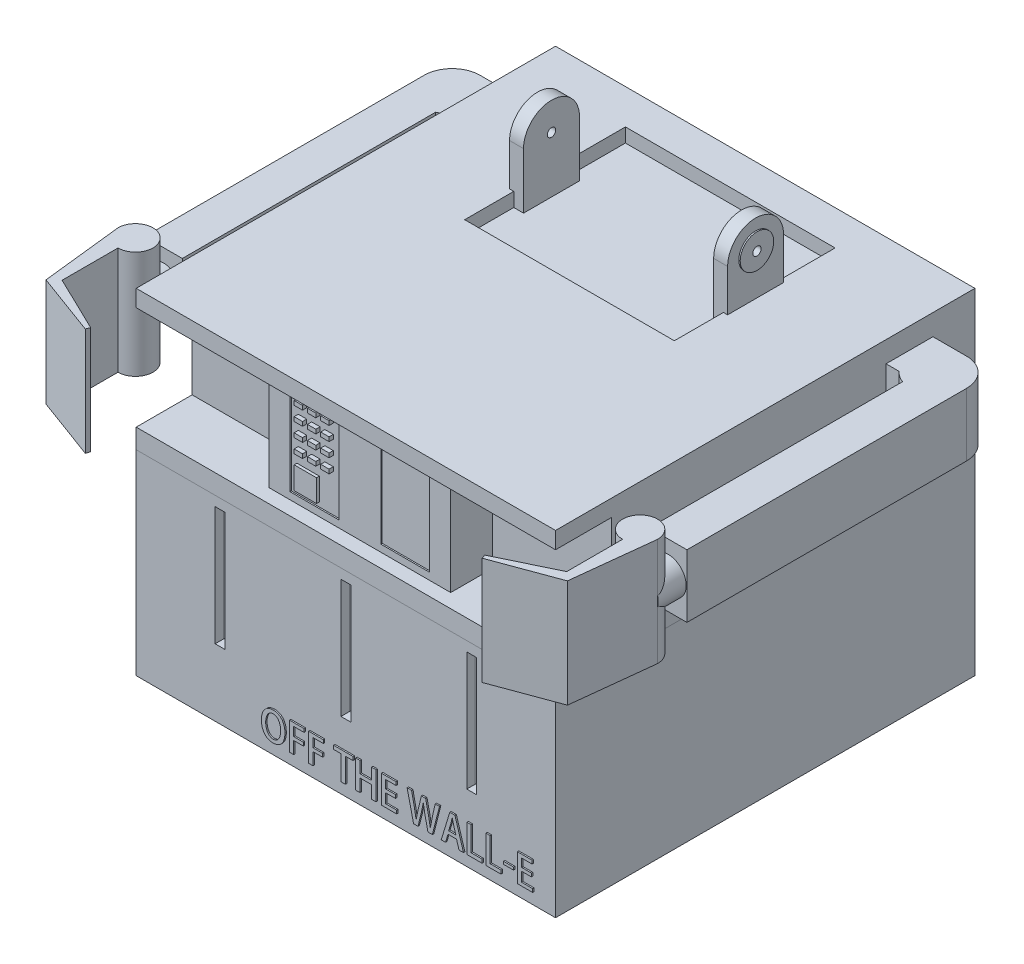
from build123d import *

# Parameters (mm, degrees)
BASE_W                                = 15
BASE_H                                = 15
BOTTOM_BASE_DEPTH                     = 7
BASE2_W                               = 15
BASE2_H                               = 15
TOP_BASE_DEPTH                        = 5
SKETCH3_W                             = 15
SKETCH3_H                             = 3.7
TOP_CUT_DEPTH                         = 2
SKETCH4_W                             = 6.5
SKETCH4_H                             = 3.7
BIG_BUTTON_PLATE_DEPTH                = 1.5
SKETCH6_W                             = 0.3
SKETCH6_H                             = 0.15
F_3X4_BUTTONS_DEPTH                   = 0.1
SKETCH9_W                             = 0.8
SKETCH9_H                             = 0.8
BIG_SQUARE_BUTTON_DEPTH               = 0.1
SKETCH6_6_W                           = 1.75
SKETCH6_6_H                           = 3.2
SKETCH6_6_W_2                         = 0.3
SKETCH6_6_H_2                         = 0.15
PHONE_DEPTH                           = 0.05
SKETCH14_W                            = 0.35
SKETCH14_H                            = 4.25
F_3_BOTTOM_SLOTS_DEPTH                = 0.35
FILLET1_R                             = 0.05
SKETCH15_W                            = 7.5
SKETCH15_H                            = 5.75
TOP_EXTRUDE_CUT_DEPTH                 = 0.5
RIGHT_HEAD_HOLDER_1_DEPTH             = 0.35
RIGHT_HEAD_HOLDER_1_DEPTH_BACK        = 0.15
SKETCH19_R                            = 0.6
RIGHT_HEAD_HOLDER_2_DEPTH             = 0.35
RIGHT_HEAD_HOLDER_2_DEPTH_BACK        = 0.2
SKETCH19_3_R                          = 0.6
SKETCH19_3_R_2                        = 0.15
LEFT_HEAD_HOLDER_1_DEPTH              = 0.35
LEFT_HEAD_HOLDER_1_DEPTH_BACK         = 0.15
SKETCH18_R                            = 0.6
LEFT_HEAD_HOLDER_2_DEPTH              = 0.35
LEFT_HEAD_HOLDER_2_DEPTH_BACK         = 0.2
SKETCH18_3_R                          = 0.6
SKETCH18_3_R_2                        = 0.15
ARMS_DEPTH                            = 2.25
CLAWS_DEPTH                           = 0.8
CLAWS_DEPTH_BACK                      = 3.05
CLAWS_2_DEPTH                         = 0.8
CLAWS_2_DEPTH_BACK                    = 3.05
SKETCH26_R                            = 0.65
CIRCLE_TO_ATTACH_ARMS_AND_CLAWS_DEPTH = 1
SKETCH28_W                            = 0.359189424
SKETCH28_H                            = 0.095238297
BOSS_EXTRUDE26_DEPTH                  = 0.05


with BuildPart() as part:
    # Base → Bottom base (new body)
    with BuildSketch(Plane(origin=(0, 0, 0), x_dir=(1, 0, 0), z_dir=(0, 1, 0))):
        Rectangle(BASE_W, BASE_H)
    extrude(amount=BOTTOM_BASE_DEPTH)

    # Sketch14 → 3 bottom slots (cut)
    with BuildSketch(Plane.XY.offset(7.5)):
        with Locations((0, 4.525)):
            Rectangle(SKETCH14_W, SKETCH14_H)
        with Locations((4.5, 4.525)):
            Rectangle(SKETCH14_W, SKETCH14_H)
        with Locations((-4.5, 4.525)):
            Rectangle(SKETCH14_W, SKETCH14_H)
    extrude(amount=-F_3_BOTTOM_SLOTS_DEPTH, mode=Mode.SUBTRACT)

    # Fillet1
    fillet1_edges = [part.edges().sort_by_distance(p)[0] for p in [
        (-0.175, 4.525, 7.15),
        (-4.675, 4.525, 7.15),
        (4.675, 4.525, 7.15),
        (4.5, 6.65, 7.15),
        (0.175, 4.525, 7.15),
        (0, 6.65, 7.15),
        (4.325, 4.525, 7.15),
        (4.5, 2.4, 7.15),
        (0, 2.4, 7.15),
        (-4.5, 2.4, 7.15),
        (-4.5, 6.65, 7.15),
        (-4.325, 4.525, 7.15),
    ]]
    fillet(fillet1_edges, radius=FILLET1_R)

    # Sketch28 → Boss-Extrude26 (add)
    # profile 1 of 12: a face of its own
    with BuildSketch(Plane.XY.offset(7.5)):
        with BuildLine():
            add(Edge.make_bspline(
                [(-2.542773415, 1.438775136), (-2.55882584, 1.438110923), (-2.59017136, 1.436813916), (-2.635834672, 1.429654226), (-2.678976734, 1.41865114), (-2.719463386, 1.403035452), (-2.757423202, 1.38326681), (-2.792716073, 1.359116703), (-2.825399223, 1.330752787), (-2.855279169, 1.298345473), (-2.882055278, 1.262197262), (-2.905669966, 1.222690536), (-2.925377124, 1.17977718), (-2.941932195, 1.133846801), (-2.954655386, 1.08466898), (-2.964079137, 1.032377645), (-2.969951963, 0.976854424), (-2.97105014, 0.938758011), (-2.971613422, 0.919217401)],
                knots=[0, 0, 0, 0, 1.01693825, 1.985772131, 2.921518734, 3.832117633, 4.727948323, 5.626511184, 6.534414133, 7.463288783, 8.412839634, 9.378967074, 10.373196777, 11.399194858, 12.46754142, 13.586614818, 14.762113956, 16, 16, 16, 16], degree=3))
            add(Edge.make_bspline(
                [(-2.971613422, 0.919217401), (-2.971208289, 0.900429172), (-2.970416523, 0.863710668), (-2.964426968, 0.810220053), (-2.956119813, 0.759588063), (-2.943575482, 0.712087769), (-2.928381776, 0.667333139), (-2.909052276, 0.625858504), (-2.886964026, 0.587076746), (-2.8612577, 0.55170149), (-2.832800775, 0.519545639), (-2.801228268, 0.491619405), (-2.766992422, 0.46781399), (-2.730017847, 0.448191723), (-2.690284694, 0.432873966), (-2.647883002, 0.421784598), (-2.602861971, 0.414647273), (-2.571917352, 0.413420404), (-2.556080466, 0.412792516)],
                knots=[0, 0, 0, 0, 1.222557966, 2.38928844, 3.500048728, 4.559063003, 5.583344684, 6.572073494, 7.532658458, 8.483942143, 9.413076429, 10.322121769, 11.220566177, 12.121066096, 13.040014193, 13.985715855, 14.969126498, 16, 16, 16, 16], degree=3))
            add(Edge.make_bspline(
                [(-2.556080466, 0.412792516), (-2.54075349, 0.413188806), (-2.510669922, 0.41396664), (-2.466682885, 0.420165519), (-2.424842983, 0.430077083), (-2.38526705, 0.444305975), (-2.348009795, 0.462822842), (-2.312864376, 0.485189664), (-2.279982063, 0.511738917), (-2.249253561, 0.542102642), (-2.221648907, 0.576876857), (-2.197202941, 0.615672953), (-2.176945288, 0.65894639), (-2.159942527, 0.706133976), (-2.146555767, 0.757497133), (-2.136920145, 0.812927523), (-2.130587189, 0.872528944), (-2.12942961, 0.913657954), (-2.12883171, 0.934901455)],
                knots=[0, 0, 0, 0, 0.964759122, 1.89361537, 2.791129421, 3.668077106, 4.535429534, 5.405715028, 6.285894481, 7.191747456, 8.120239528, 9.075412678, 10.072429751, 11.12252868, 12.229792465, 13.410030886, 14.662257747, 16, 16, 16, 16], degree=3))
            add(Edge.make_bspline(
                [(-2.12883171, 0.934901455), (-2.129145052, 0.95299104), (-2.12975776, 0.988363246), (-2.134927432, 1.040094869), (-2.143460291, 1.089133126), (-2.154882139, 1.135699503), (-2.169797366, 1.179671389), (-2.188169567, 1.221026594), (-2.209857994, 1.259758826), (-2.234383469, 1.295895008), (-2.262423291, 1.328524563), (-2.293489849, 1.357214635), (-2.327622631, 1.381751634), (-2.365000455, 1.401492806), (-2.405152647, 1.417631026), (-2.44846881, 1.428920554), (-2.494667177, 1.436482788), (-2.526508763, 1.437935279), (-2.542773415, 1.438775136)],
                knots=[0, 0, 0, 0, 1.181997023, 2.311265979, 3.393394717, 4.432710499, 5.441572568, 6.423779709, 7.385757606, 8.339154063, 9.273212536, 10.190881701, 11.096730823, 12.012033381, 12.946898792, 13.918455472, 14.931549697, 16, 16, 16, 16], degree=3))
        make_face()
        with BuildLine():
            add(Edge.make_bspline(
                [(-2.548066636, 1.31991609), (-2.537165417, 1.318983992), (-2.515855441, 1.317161903), (-2.484981242, 1.31054518), (-2.456310213, 1.300351113), (-2.429814447, 1.286594966), (-2.405742403, 1.269172675), (-2.383543332, 1.248629521), (-2.363840451, 1.224383101), (-2.346717009, 1.196948695), (-2.331589955, 1.167451879), (-2.318430785, 1.13658356), (-2.306908464, 1.104796692), (-2.29799648, 1.071757069), (-2.290669647, 1.037788882), (-2.285934581, 1.002655396), (-2.282735348, 0.966518333), (-2.282427136, 0.942026369), (-2.282270891, 0.929610449)],
                knots=[0, 0, 0, 0, 0.999589655, 1.954022852, 2.877517249, 3.773878129, 4.673599429, 5.586311784, 6.531597741, 7.520501744, 8.537853166, 9.559417173, 10.586727125, 11.626167667, 12.685579831, 13.761408337, 14.865171654, 16, 16, 16, 16], degree=3))
            add(Edge.make_bspline(
                [(-2.282270891, 0.929610449), (-2.282515675, 0.916063238), (-2.282995612, 0.889501882), (-2.28596674, 0.850426095), (-2.29128527, 0.813015414), (-2.298562117, 0.777117744), (-2.308300047, 0.742958305), (-2.31968806, 0.710261892), (-2.333651813, 0.679388185), (-2.349250923, 0.650198013), (-2.36712996, 0.623475447), (-2.387135503, 0.599901927), (-2.409359173, 0.579747293), (-2.433601588, 0.563029952), (-2.460016367, 0.549834402), (-2.488459567, 0.540284041), (-2.518878394, 0.533600178), (-2.539982794, 0.532311215), (-2.550789459, 0.531651192)],
                knots=[0, 0, 0, 0, 1.215141369, 2.382468418, 3.512223075, 4.602497428, 5.664896563, 6.695933009, 7.704955915, 8.700973005, 9.661508233, 10.583141316, 11.467103885, 12.344670232, 13.216342825, 14.106081872, 15.030205112, 16, 16, 16, 16], degree=3))
            add(Edge.make_bspline(
                [(-2.550789459, 0.531651192), (-2.561404923, 0.532397393), (-2.582186513, 0.53385821), (-2.612268391, 0.540448671), (-2.640452786, 0.550215414), (-2.666522509, 0.563599601), (-2.690700767, 0.580196186), (-2.712602066, 0.600478458), (-2.732893267, 0.623866029), (-2.750494325, 0.650723065), (-2.766275355, 0.679738522), (-2.7800325, 0.710402286), (-2.791879883, 0.742433556), (-2.80114964, 0.77598823), (-2.808854497, 0.810774186), (-2.814005122, 0.846973579), (-2.817330483, 0.884511626), (-2.817764383, 0.910013807), (-2.817985276, 0.922996691)],
                knots=[0, 0, 0, 0, 0.968573833, 1.896149455, 2.796477749, 3.679461465, 4.558257033, 5.460120664, 6.392036362, 7.372592241, 8.379386201, 9.399199485, 10.432362265, 11.48798156, 12.568687675, 13.676620176, 14.817192429, 16, 16, 16, 16], degree=3))
            add(Edge.make_bspline(
                [(-2.817985276, 0.922996691), (-2.817906472, 0.93566455), (-2.817750586, 0.960723784), (-2.814512109, 0.997678677), (-2.809767876, 1.033623912), (-2.802495327, 1.068302048), (-2.793463414, 1.101907221), (-2.782305831, 1.13439706), (-2.768830302, 1.165645515), (-2.753760089, 1.19566964), (-2.736462485, 1.223413999), (-2.716446665, 1.247918927), (-2.69405673, 1.268812858), (-2.669357094, 1.286293929), (-2.642284347, 1.300124753), (-2.612952929, 1.310551542), (-2.58132124, 1.317484158), (-2.559390721, 1.319029602), (-2.548066636, 1.31991609)],
                knots=[0, 0, 0, 0, 1.136547726, 2.248289582, 3.326834991, 4.389002452, 5.425786828, 6.448433384, 7.469124786, 8.477926495, 9.461316408, 10.397265518, 11.309260955, 12.201738065, 13.104381261, 14.028854752, 14.989125284, 16, 16, 16, 16], degree=3))
        make_face(mode=Mode.SUBTRACT)
    # profile 2 of 12: a face of its own
    with BuildSketch(Plane.XY.offset(7.5)):
        Polygon((-1.814205801, 0.421490419), (-1.814205801, 0.860354587), (-1.471996241, 0.860354587), (-1.471996241, 0.979213633), (-1.814205801, 0.979213633), (-1.814205801, 1.295728633), (-1.445873374, 1.295728633), (-1.445873374, 1.414587678), (-1.967645167, 1.414587678), (-1.967645167, 0.421490419), align=None)
    # profile 3 of 12: a face of its own
    with BuildSketch(Plane.XY.offset(7.5)):
        Polygon((-1.12486327, 0.421490419), (-1.12486327, 0.860354587), (-0.782653711, 0.860354587), (-0.782653711, 0.979213633), (-1.12486327, 0.979213633), (-1.12486327, 1.295728633), (-0.756530843, 1.295728633), (-0.756530843, 1.414587678), (-1.278302637, 1.414587678), (-1.278302637, 0.421490419), align=None)
    # profile 4 of 12: a face of its own
    with BuildSketch(Plane.XY.offset(7.5)):
        Polygon((0.306506351, 1.425859116), (-0.386370222, 1.425859116), (-0.386370222, 1.296550924), (-0.11730469, 1.296550924), (-0.11730469, 0.426659447), (0.036134676, 0.426659447), (0.036134676, 1.296550924), (0.306506351, 1.296550924), align=None)
    # profile 5 of 12: a face of its own
    with BuildSketch(Plane.XY.offset(7.5)):
        Polygon((1.124570067, 1.428519382), (0.971130701, 1.428519382), (0.971130701, 1.015778081), (0.556165007, 1.015778081), (0.556165007, 1.428519382), (0.40272564, 1.428519382), (0.40272564, 0.429720894), (0.556165007, 0.429720894), (0.556165007, 0.884258782), (0.971130701, 0.884258782), (0.971130701, 0.429720894), (1.124570067, 0.429720894), align=None)
    # profile 6 of 12: a face of its own
    with BuildSketch(Plane.XY.offset(7.5)):
        Polygon((1.868437532, 0.543839587), (1.475288381, 0.543839587), (1.475288381, 0.884542045), (1.825334801, 0.884542045), (1.825334801, 1.00340109), (1.475288381, 1.00340109), (1.475288381, 1.295728633), (1.846233095, 1.295728633), (1.846233095, 1.414587678), (1.321849015, 1.414587678), (1.321849015, 0.424980542), (1.868437532, 0.424980542), align=None)
    # profile 7 of 12: a face of its own
    with BuildSketch(Plane.XY.offset(7.5)):
        with BuildLine():
            Line((3.245765887, 1.425831067), (3.139055562, 0.953960298))
            add(Edge.make_bspline(
                [(3.139055562, 0.953960298), (3.132663135, 0.924375836), (3.119998725, 0.865764336), (3.1020337, 0.778168135), (3.085930576, 0.690954756), (3.07705063, 0.63264649), (3.07260538, 0.603457706)],
                knots=[0, 0, 0, 0, 1.01788206, 2.01658543, 3.007114032, 4, 4, 4, 4], degree=3))
            Line((3.07260538, 0.603457706), (3.068782909, 0.603457706))
            add(Edge.make_bspline(
                [(3.068782909, 0.603457706), (3.064621305, 0.632259681), (3.056258443, 0.690138076), (3.041702599, 0.777037426), (3.025081799, 0.864413942), (3.012568145, 0.922642729), (3.006278837, 0.951908261)],
                knots=[0, 0, 0, 0, 0.986163973, 1.981724799, 2.985623747, 4, 4, 4, 4], degree=3))
            Line((3.006278837, 0.951908261), (2.902210694, 1.426964854))
            Line((2.902210694, 1.426964854), (2.751254624, 1.426964854))
            Line((2.751254624, 1.426964854), (2.638037571, 0.954592148))
            add(Edge.make_bspline(
                [(2.638037571, 0.954592148), (2.630872403, 0.923406884), (2.61681508, 0.862224604), (2.596699251, 0.772299255), (2.578665214, 0.686135246), (2.569505115, 0.629634853), (2.565046708, 0.602134954)],
                knots=[0, 0, 0, 0, 1.066520868, 2.092404214, 3.071534041, 4, 4, 4, 4], degree=3))
            Line((2.565046708, 0.602134954), (2.562559536, 0.602140121))
            add(Edge.make_bspline(
                [(2.562559536, 0.602140121), (2.560300099, 0.615428557), (2.55570602, 0.642447728), (2.54874011, 0.683653591), (2.541417455, 0.726190662), (2.530665073, 0.785077644), (2.516739752, 0.860534551), (2.504767173, 0.921245095), (2.498720165, 0.951908261)],
                knots=[0, 0, 0, 0, 0.682369738, 1.387451828, 2.115611866, 2.867419731, 4.417822979, 6, 6, 6, 6], degree=3))
            Line((2.498720165, 0.951908261), (2.399891357, 1.426964854))
            Line((2.399891357, 1.426964854), (2.239838602, 1.426964854))
            Line((2.239838602, 1.426964854), (2.472766701, 0.425831067))
            Line((2.472766701, 0.425831067), (2.631530844, 0.425831067))
            Line((2.631530844, 0.425831067), (2.749953278, 0.910045241))
            add(Edge.make_bspline(
                [(2.749953278, 0.910045241), (2.753617344, 0.924555813), (2.760831191, 0.953124366), (2.770726599, 0.995475919), (2.780283244, 1.03650652), (2.791843212, 1.089662653), (2.80499902, 1.155496718), (2.813336322, 1.208364765), (2.817503292, 1.234788132)],
                knots=[0, 0, 0, 0, 0.811805786, 1.598290927, 2.359154387, 3.097023541, 4.549096894, 6, 6, 6, 6], degree=3))
            Line((2.817503292, 1.234788132), (2.821527277, 1.234976727))
            add(Edge.make_bspline(
                [(2.821527277, 1.234976727), (2.82469568, 1.208365765), (2.831034187, 1.155129548), (2.844522693, 1.075106184), (2.860318642, 0.993345399), (2.872490004, 0.938213226), (2.878727794, 0.90995814)],
                knots=[0, 0, 0, 0, 0.973823886, 1.948170723, 2.948443182, 4, 4, 4, 4], degree=3))
            Line((2.878727794, 0.90995814), (2.986798147, 0.425831067))
            Line((2.986798147, 0.425831067), (3.144260944, 0.425831067))
            Line((3.144260944, 0.425831067), (3.399324648, 1.426964854))
            Line((3.399324648, 1.426964854), (3.245765887, 1.425831067))
        make_face()
    # profile 8 of 12: a face of its own
    with BuildSketch(Plane.XY.offset(7.5)):
        Polygon((3.9523852, 1.426512188), (3.766939047, 1.426512188), (3.461305192, 0.421347588), (3.616753782, 0.421347588), (3.702947065, 0.715229844), (4.008541429, 0.715229844), (4.098652588, 0.421347588), (4.257979564, 0.421347588), align=None)
        with BuildLine():
            Line((3.726454323, 0.83408889), (3.806117812, 1.098552471))
            add(Edge.make_bspline(
                [(3.806117812, 1.098552471), (3.810378493, 1.114590054), (3.819076241, 1.147329146), (3.83055211, 1.197153881), (3.841903727, 1.246876142), (3.849377993, 1.279761021), (3.853028805, 1.295823669)],
                knots=[0, 0, 0, 0, 0.981880665, 2.004409445, 3.025252049, 4, 4, 4, 4], degree=3))
            Line((3.853028805, 1.295823669), (3.855744247, 1.295897852))
            add(Edge.make_bspline(
                [(3.855744247, 1.295897852), (3.859406222, 1.279929837), (3.866906617, 1.247224421), (3.878892873, 1.19768297), (3.891585867, 1.147389791), (3.900662415, 1.113901091), (3.905183009, 1.097221969)],
                knots=[0, 0, 0, 0, 0.960134074, 1.966530216, 2.987225846, 4, 4, 4, 4], degree=3))
            Line((3.905183009, 1.097221969), (3.983728212, 0.83408889))
            Line((3.983728212, 0.83408889), (3.726454323, 0.83408889))
        make_face(mode=Mode.SUBTRACT)
    # profile 9 of 12: a face of its own
    with BuildSketch(Plane.XY.offset(7.5)):
        Polygon((4.92031401, 0.555082791), (4.53500172, 0.555082791), (4.53500172, 1.426280411), (4.381562353, 1.426280411), (4.381562353, 0.425831067), (4.92031401, 0.425831067), align=None)
    # profile 10 of 12: a face of its own
    with BuildSketch(Plane.XY.offset(7.5)):
        Polygon((5.597562813, 0.555082791), (5.212250522, 0.555082791), (5.212250522, 1.426280411), (5.058811156, 1.426280411), (5.058811156, 0.425831067), (5.597562813, 0.425831067), align=None)
    # profile 11 of 12: a face of its own
    with BuildSketch(Plane.XY.offset(7.5)):
        with Locations((5.867201512, 0.823034374)):
            Rectangle(SKETCH28_W, SKETCH28_H)
    # profile 12 of 12: a face of its own
    with BuildSketch(Plane.XY.offset(7.5)):
        Polygon((6.730116434, 0.543839587), (6.336967283, 0.543839587), (6.336967283, 0.884542045), (6.687013703, 0.884542045), (6.687013703, 1.00340109), (6.336967283, 1.00340109), (6.336967283, 1.295728633), (6.707911996, 1.295728633), (6.707911996, 1.414587678), (6.183527917, 1.414587678), (6.183527917, 0.424980542), (6.730116434, 0.424980542), align=None)
    extrude(amount=BOSS_EXTRUDE26_DEPTH)


with BuildPart() as body_2:
    # Base2 → Top base (new body)
    with BuildSketch(Plane(origin=(0, 7, 0), x_dir=(1, 0, 0), z_dir=(0, 1, 0))):
        Rectangle(BASE2_W, BASE2_H)
    extrude(amount=TOP_BASE_DEPTH)

    # Sketch3 → Top cut (cut)
    with BuildSketch(Plane.XY.offset(7.5)):
        with Locations((0, 9.55)):
            Rectangle(SKETCH3_W, SKETCH3_H)
    extrude(amount=-TOP_CUT_DEPTH, mode=Mode.SUBTRACT)

    # Sketch4 → Big button plate (add)
    with BuildSketch(Plane.XY.offset(5.5)):
        with Locations((0, 9.55)):
            Rectangle(SKETCH4_W, SKETCH4_H)
    extrude(amount=BIG_BUTTON_PLATE_DEPTH)

    # Sketch6 → 3x4 buttons (add)
    with BuildSketch(Plane.XY.offset(7)):
        with Locations((-1.625, 10.874059361)):
            Rectangle(SKETCH6_W, SKETCH6_H)
        with Locations((-2.1, 10.874059361)):
            Rectangle(SKETCH6_W, SKETCH6_H)
        with Locations((-1.15, 10.874059361)):
            Rectangle(SKETCH6_W, SKETCH6_H)
        with Locations((-2.1, 10.374059361)):
            Rectangle(SKETCH6_W, SKETCH6_H)
        with Locations((-1.625, 10.374059361)):
            Rectangle(SKETCH6_W, SKETCH6_H)
        with Locations((-1.15, 10.374059361)):
            Rectangle(SKETCH6_W, SKETCH6_H)
        with Locations((-2.1, 9.874059361)):
            Rectangle(SKETCH6_W, SKETCH6_H)
        with Locations((-1.625, 9.874059361)):
            Rectangle(SKETCH6_W, SKETCH6_H)
        with Locations((-1.15, 9.874059361)):
            Rectangle(SKETCH6_W, SKETCH6_H)
        with Locations((-2.1, 9.374059361)):
            Rectangle(SKETCH6_W, SKETCH6_H)
        with Locations((-1.625, 9.374059361)):
            Rectangle(SKETCH6_W, SKETCH6_H)
        with Locations((-1.15, 9.374059361)):
            Rectangle(SKETCH6_W, SKETCH6_H)
    extrude(amount=F_3X4_BUTTONS_DEPTH)

    # Sketch9 → Big square button (add)
    with BuildSketch(Plane.XY.offset(7)):
        with Locations((-1.85, 8.55732297)):
            Rectangle(SKETCH9_W, SKETCH9_H)
    extrude(amount=BIG_SQUARE_BUTTON_DEPTH)

    # Sketch6_6 → phone (cut)
    # profile 1 of 2: a face of its own
    with BuildSketch(Plane.XY.offset(7)):
        with Locations((-1.625, 9.55)):
            Rectangle(SKETCH6_6_W, SKETCH6_6_H)
        with Locations((-1.625, 10.874059361)):
            Rectangle(SKETCH6_6_W_2, SKETCH6_6_H_2, mode=Mode.SUBTRACT)
        with Locations((-2.1, 10.874059361)):
            Rectangle(SKETCH6_6_W_2, SKETCH6_6_H_2, mode=Mode.SUBTRACT)
        with Locations((-1.15, 10.874059361)):
            Rectangle(SKETCH6_6_W_2, SKETCH6_6_H_2, mode=Mode.SUBTRACT)
        with Locations((-2.1, 10.374059361)):
            Rectangle(SKETCH6_6_W_2, SKETCH6_6_H_2, mode=Mode.SUBTRACT)
        with Locations((-1.625, 10.374059361)):
            Rectangle(SKETCH6_6_W_2, SKETCH6_6_H_2, mode=Mode.SUBTRACT)
        with Locations((-1.15, 10.374059361)):
            Rectangle(SKETCH6_6_W_2, SKETCH6_6_H_2, mode=Mode.SUBTRACT)
        with Locations((-2.1, 9.874059361)):
            Rectangle(SKETCH6_6_W_2, SKETCH6_6_H_2, mode=Mode.SUBTRACT)
        with Locations((-1.625, 9.874059361)):
            Rectangle(SKETCH6_6_W_2, SKETCH6_6_H_2, mode=Mode.SUBTRACT)
        with Locations((-1.15, 9.874059361)):
            Rectangle(SKETCH6_6_W_2, SKETCH6_6_H_2, mode=Mode.SUBTRACT)
        with Locations((-2.1, 9.374059361)):
            Rectangle(SKETCH6_6_W_2, SKETCH6_6_H_2, mode=Mode.SUBTRACT)
        with Locations((-1.625, 9.374059361)):
            Rectangle(SKETCH6_6_W_2, SKETCH6_6_H_2, mode=Mode.SUBTRACT)
        with Locations((-1.15, 9.374059361)):
            Rectangle(SKETCH6_6_W_2, SKETCH6_6_H_2, mode=Mode.SUBTRACT)
    # profile 2 of 2: a face of its own
    with BuildSketch(Plane.XY.offset(7)):
        with Locations((1.625, 9.55)):
            Rectangle(SKETCH6_6_W, SKETCH6_6_H)
    extrude(amount=-PHONE_DEPTH, mode=Mode.SUBTRACT)


with BuildPart() as phone_piece_1:
    # of the separate pieces the step leaves, piece 1, a body of its own (phone_pieces)
    add(body_2.part.solids().sort_by_distance((-7.5, 7, 7.5))[0])

    # Sketch15 → Top extrude cut (cut)
    with BuildSketch(Plane(origin=(0, 12, 0), x_dir=(1, 0, 0), z_dir=(0, 1, 0))):
        with Locations((0, 3.375)):
            Rectangle(SKETCH15_W, SKETCH15_H)
    extrude(amount=-TOP_EXTRUDE_CUT_DEPTH, mode=Mode.SUBTRACT)

    # Sketch19 → Right head holder 1 (add, two sides: drawn at the far end of the back side and taken through both)
    with BuildSketch(Plane.ZY.offset(-3.75).offset(-RIGHT_HEAD_HOLDER_1_DEPTH_BACK)):
        with BuildLine():
            ThreePointArc((-2.255590817, 13.5), (-3.255590817, 14.5), (-4.255590817, 13.5))
            Line((-4.255590817, 13.5), (-4.255590817, 11.5))
            Line((-4.255590817, 11.5), (-2.255590817, 11.5))
            Line((-2.255590817, 11.5), (-2.255590817, 13.5))
        make_face()
        with Locations((-3.255590817, 13.5)):
            Circle(SKETCH19_R, mode=Mode.SUBTRACT)
    extrude(amount=RIGHT_HEAD_HOLDER_1_DEPTH + RIGHT_HEAD_HOLDER_1_DEPTH_BACK)

    # Sketch19_3 → Right head holder 2 (add, two sides: drawn at the far end of the back side and taken through both)
    with BuildSketch(Plane.ZY.offset(-3.75).offset(-RIGHT_HEAD_HOLDER_2_DEPTH_BACK)):
        with Locations((-3.255590817, 13.5)):
            Circle(SKETCH19_3_R)
        with Locations((-3.255590817, 13.5)):
            Circle(SKETCH19_3_R_2, mode=Mode.SUBTRACT)
    extrude(amount=RIGHT_HEAD_HOLDER_2_DEPTH + RIGHT_HEAD_HOLDER_2_DEPTH_BACK)

    # Sketch18 → Left head holder 1 (add, two sides: drawn at the far end of the back side and taken through both)
    with BuildSketch(Plane(origin=(-3.75, 0, 0), x_dir=(0, 0, -1), z_dir=(1, 0, 0)).offset(-LEFT_HEAD_HOLDER_1_DEPTH_BACK)):
        with BuildLine():
            Line((2.255590817, 11.5), (4.255590817, 11.5))
            Line((4.255590817, 11.5), (4.255590817, 13.5))
            ThreePointArc((4.255590817, 13.5), (3.255590817, 14.5), (2.255590817, 13.5))
            Line((2.255590817, 13.5), (2.255590817, 11.5))
        make_face()
        with Locations((3.255590817, 13.5)):
            Circle(SKETCH18_R, mode=Mode.SUBTRACT)
    extrude(amount=LEFT_HEAD_HOLDER_1_DEPTH + LEFT_HEAD_HOLDER_1_DEPTH_BACK)

    # Sketch18_3 → Left head holder 2 (add, two sides: drawn at the far end of the back side and taken through both)
    with BuildSketch(Plane(origin=(-3.75, 0, 0), x_dir=(0, 0, -1), z_dir=(1, 0, 0)).offset(-LEFT_HEAD_HOLDER_2_DEPTH_BACK)):
        with Locations((3.255590817, 13.5)):
            Circle(SKETCH18_3_R)
        with Locations((3.255590817, 13.5)):
            Circle(SKETCH18_3_R_2, mode=Mode.SUBTRACT)
    extrude(amount=LEFT_HEAD_HOLDER_2_DEPTH + LEFT_HEAD_HOLDER_2_DEPTH_BACK)

    # Sketch21 → arms (add)
    with BuildSketch(Plane(origin=(0, 9, 0), x_dir=(1, 0, 0), z_dir=(0, 1, 0))):
        with BuildLine():
            Line((7.5, 4.322915521), (7.964094701, 4.322915521))
            ThreePointArc((7.964094701, 4.322915521), (8.141740127, 4.170333854), (8.35, 4.0632503))
            Line((8.35, 4.0632503), (8.35, -5))
            Line((8.35, -5), (9.7, -5))
            Line((9.7, -5), (9.7, 5))
            ThreePointArc((9.7, 5), (9.407106781, 5.707106781), (8.7, 6))
            Line((8.7, 6), (7.5, 6))
            Line((7.5, 6), (7.5, 4.322915521))
        make_face()
        with BuildLine():
            Line((-7.5, 6), (-8.7, 6))
            ThreePointArc((-8.7, 6), (-9.407106781, 5.707106781), (-9.7, 5))
            Line((-9.7, 5), (-9.7, -5))
            Line((-9.7, -5), (-8.35, -5))
            Line((-8.35, -5), (-8.35, 4.0632503))
            ThreePointArc((-8.35, 4.0632503), (-8.141740127, 4.170333854), (-7.964094701, 4.322915521))
            Line((-7.964094701, 4.322915521), (-7.5, 4.322915521))
            Line((-7.5, 4.322915521), (-7.5, 6))
        make_face()
    extrude(amount=ARMS_DEPTH)



with BuildPart() as phone_piece_2:
    # of the separate pieces the step leaves, piece 2, a body of its own (phone_pieces)
    add(body_2.part.solids().sort_by_distance((-2.25, 8.95732297, 7))[0])


with BuildPart() as body_4:
    # Sketch25 → claws (new, two sides: drawn at the far end of the back side and taken through both)
    with BuildSketch(Plane(origin=(0, 11.25, 0), x_dir=(1, 0, 0), z_dir=(0, 1, 0)).offset(-CLAWS_DEPTH_BACK)):
        with BuildLine():
            ThreePointArc((9.65, -6), (8.583058262, -5.558058262), (9.025, -6.625))
            Line((9.025, -6.625), (9.025, -8.625))
            Line((9.025, -8.625), (7.048208811, -9.580762133))
            Line((7.048208811, -9.580762133), (7.100145112, -9.721483918))
            Line((7.100145112, -9.721483918), (9.325961764, -8.9))
            Line((9.325961764, -8.9), (9.65, -6))
        make_face()
    extrude(amount=CLAWS_DEPTH + CLAWS_DEPTH_BACK)


with BuildPart() as body_5:
    # Sketch25 → claws 2 (new, two sides: drawn at the far end of the back side and taken through both)
    with BuildSketch(Plane(origin=(0, 11.25, 0), x_dir=(1, 0, 0), z_dir=(0, 1, 0)).offset(-CLAWS_2_DEPTH_BACK)):
        with BuildLine():
            Line((-9.325961764, -8.9), (-7.100145112, -9.721483918))
            Line((-7.100145112, -9.721483918), (-7.048208811, -9.580762133))
            Line((-7.048208811, -9.580762133), (-9.025, -8.625))
            Line((-9.025, -8.625), (-9.025, -6.625))
            ThreePointArc((-9.025, -6.625), (-8.583058262, -5.558058262), (-9.65, -6))
            Line((-9.65, -6), (-9.325961764, -8.9))
        make_face()
    extrude(amount=CLAWS_2_DEPTH + CLAWS_2_DEPTH_BACK)


with BuildPart() as phone_piece_1_1:
    add(phone_piece_1.part)

    add(body_4.part)  # circle to attach arms and claws merges body 4

    add(body_5.part)  # circle to attach arms and claws merges body 5
    # Sketch26 → circle to attach arms and claws (add)
    with BuildSketch(Plane.XY.offset(5)):
        with Locations((9.025, 10.125)):
            Circle(SKETCH26_R)
        with Locations((-9.025, 10.125)):
            Circle(SKETCH26_R)
    extrude(amount=CIRCLE_TO_ATTACH_ARMS_AND_CLAWS_DEPTH)


solid = Compound([part.part, phone_piece_2.part, phone_piece_1_1.part])
